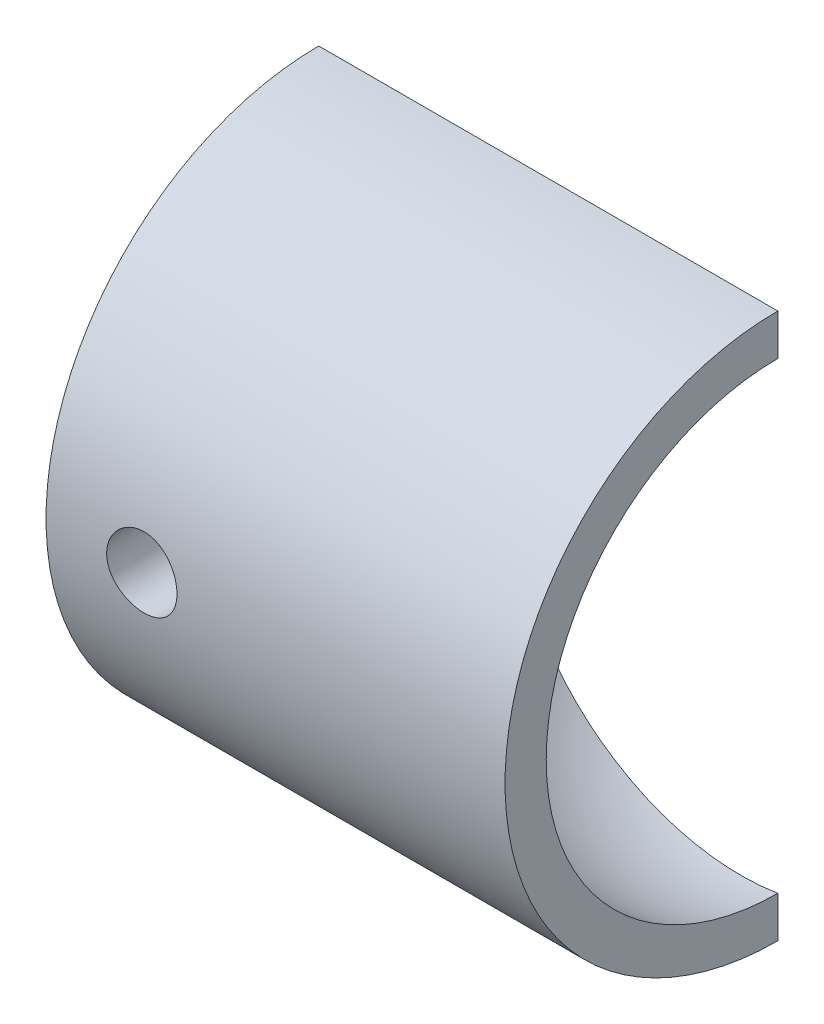
from build123d import *

# Parameters (mm, degrees)
CORTAR_EXTRUIR1_DEPTH = 50
CROQUIS4_R            = 1.5
CORTAR_EXTRUIR2_DEPTH = 20


with BuildPart() as part:
    # Croquis1 → Revolución1 (revolve)
    with BuildSketch(Plane(origin=(0, 0, 0), x_dir=(1, 0, 0), z_dir=(0, 1, 0))):
        with BuildLine():
            Line((-10, 0), (-18, 0))
            Line((-18, 0), (-18, 11.630777084))
            Line((-18, 11.630777084), (1.574675275, 11.630777084))
            Line((1.574675275, 11.630777084), (1.574675275, 9.875241657))
            ThreePointArc((1.574675275, 9.875241657), (-6.490502571, 7.607455315), (-10, 0))
        make_face()
    revolve(axis=Axis((-10, 0, 0), (-1, 0, 0)))

    # Croquis3 → Cortar-Extruir1 (cut)
    with BuildSketch(Plane(origin=(1.574675275, 0, 0), x_dir=(0, 0, -1), z_dir=(1, 0, 0))):
        Polygon((0, 0), (0, -16.586651977), (12.985125339, -16.586651977), (12.985125339, 15.917262398), (0, 15.917262398), align=None)
    extrude(amount=-CORTAR_EXTRUIR1_DEPTH, mode=Mode.SUBTRACT)

    # Croquis4 → Cortar-Extruir2 (cut)
    with BuildSketch(Plane(origin=(0, 0, 0), x_dir=(-1, 0, 0), z_dir=(0, 0, -1))):
        with Locations((13.917030973, 0)):
            Circle(CROQUIS4_R)
    extrude(amount=-CORTAR_EXTRUIR2_DEPTH, mode=Mode.SUBTRACT)


solid = part.part
